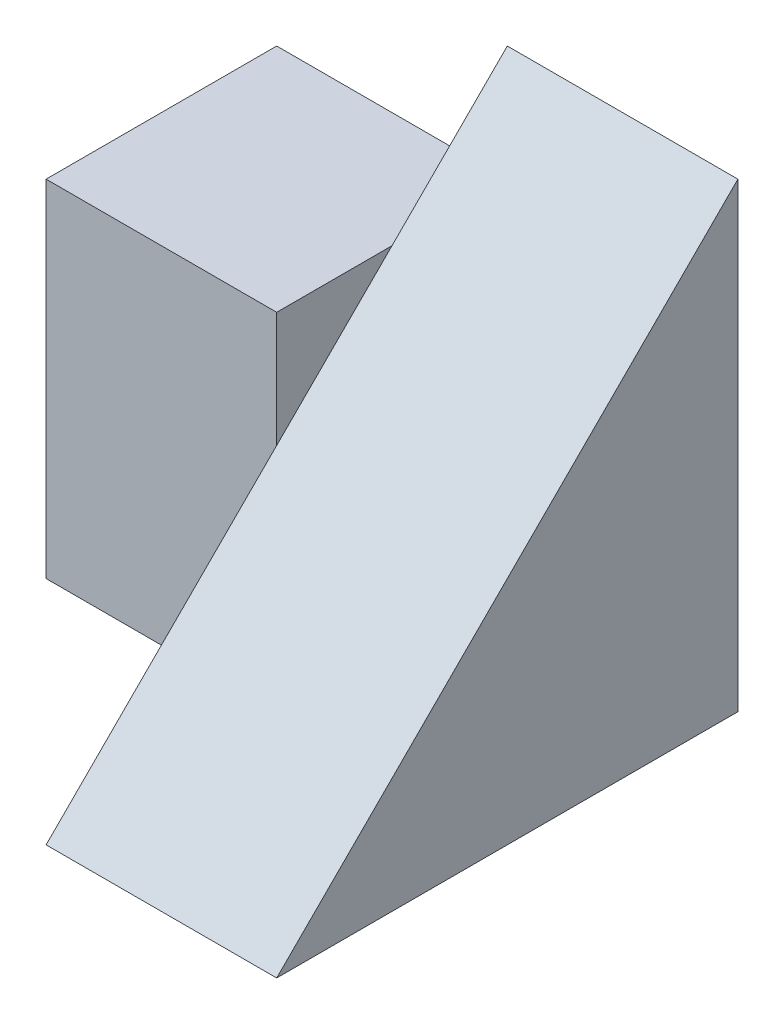
from build123d import *

# Parameters (mm, degrees)
SKETCH1_W           = 4
SKETCH1_H           = 4
BOSS_EXTRUDE1_DEPTH = 2
SKETCH2_W           = 2
SKETCH2_H           = 3
BOSS_EXTRUDE2_DEPTH = 2
CUT_EXTRUDE1_DEPTH  = 2


with BuildPart() as part:
    # Sketch1 → Boss-Extrude1 (new body)
    with BuildSketch(Plane(origin=(0, 0, 0), x_dir=(0, 0, -1), z_dir=(1, 0, 0))):
        with Locations((2, 2)):
            Rectangle(SKETCH1_W, SKETCH1_H)
    extrude(amount=BOSS_EXTRUDE1_DEPTH)

    # Sketch2 → Boss-Extrude2 (add)
    with BuildSketch(Plane.ZY):
        with Locations((-3, 1.5)):
            Rectangle(SKETCH2_W, SKETCH2_H)
    extrude(amount=BOSS_EXTRUDE2_DEPTH)

    # Sketch3 → Cut-Extrude1 (cut)
    with BuildSketch(Plane(origin=(2, 0, 0), x_dir=(0, 0, -1), z_dir=(1, 0, 0))):
        Polygon((4, 4), (0, 0), (0, 4), align=None)
    extrude(amount=-CUT_EXTRUDE1_DEPTH, mode=Mode.SUBTRACT)


solid = part.part
